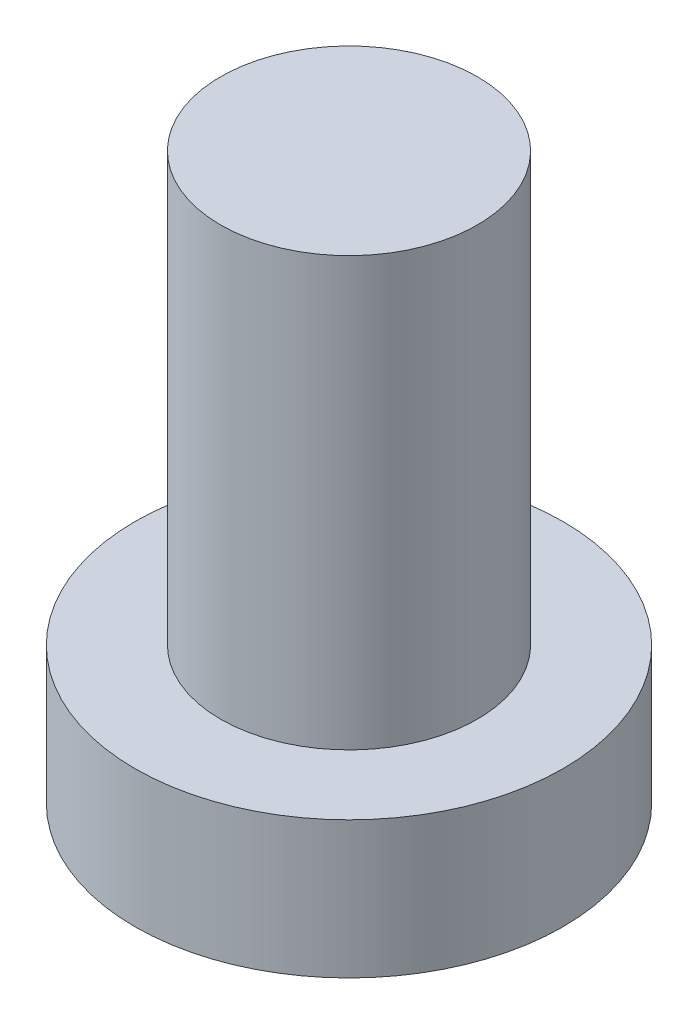
from build123d import *

# Parameters (mm, degrees)
SKETCH_1_R          = 2.5
EXTRUDE_1_DEPTH     = 1.6
SKETCH_2_R          = 1.5
EXTRUDE_2_DEPTH     = 5
CUT_EXTRUDE_1_DEPTH = 1


with BuildPart() as part:
    # 草图1 → 凸台-拉伸1 (new body)
    with BuildSketch(Plane(origin=(0, 0, 0), x_dir=(1, 0, 0), z_dir=(0, 1, 0))):
        Circle(SKETCH_1_R)
    extrude(amount=EXTRUDE_1_DEPTH)

    # 草图2 → 凸台-拉伸2 (add)
    with BuildSketch(Plane(origin=(0, 1.6, 0), x_dir=(1, 0, 0), z_dir=(0, 1, 0))):
        Circle(SKETCH_2_R)
    extrude(amount=EXTRUDE_2_DEPTH)

    # 草图3 → 切除-拉伸1 (cut)
    with BuildSketch(Plane.XZ):
        with BuildLine():
            Line((-0.5, 1), (-0.5, 1.75))
            Line((-0.5, 1.75), (0.5, 1.75))
            Line((0.5, 1.75), (0.5, 1))
            ThreePointArc((0.5, 1), (0.646446609, 0.646446609), (1, 0.5))
            Line((1, 0.5), (1.75, 0.5))
            Line((1.75, 0.5), (1.75, -0.5))
            Line((1.75, -0.5), (1, -0.5))
            ThreePointArc((1, -0.5), (0.646446609, -0.646446609), (0.5, -1))
            Line((0.5, -1), (0.5, -1.75))
            Line((0.5, -1.75), (-0.5, -1.75))
            Line((-0.5, -1.75), (-0.5, -1))
            ThreePointArc((-0.5, -1), (-0.646446609, -0.646446609), (-1, -0.5))
            Line((-1, -0.5), (-1.75, -0.5))
            Line((-1.75, -0.5), (-1.75, 0.5))
            Line((-1.75, 0.5), (-1, 0.5))
            ThreePointArc((-1, 0.5), (-0.646446609, 0.646446609), (-0.5, 1))
        make_face()
    extrude(amount=-CUT_EXTRUDE_1_DEPTH, mode=Mode.SUBTRACT)


solid = part.part
